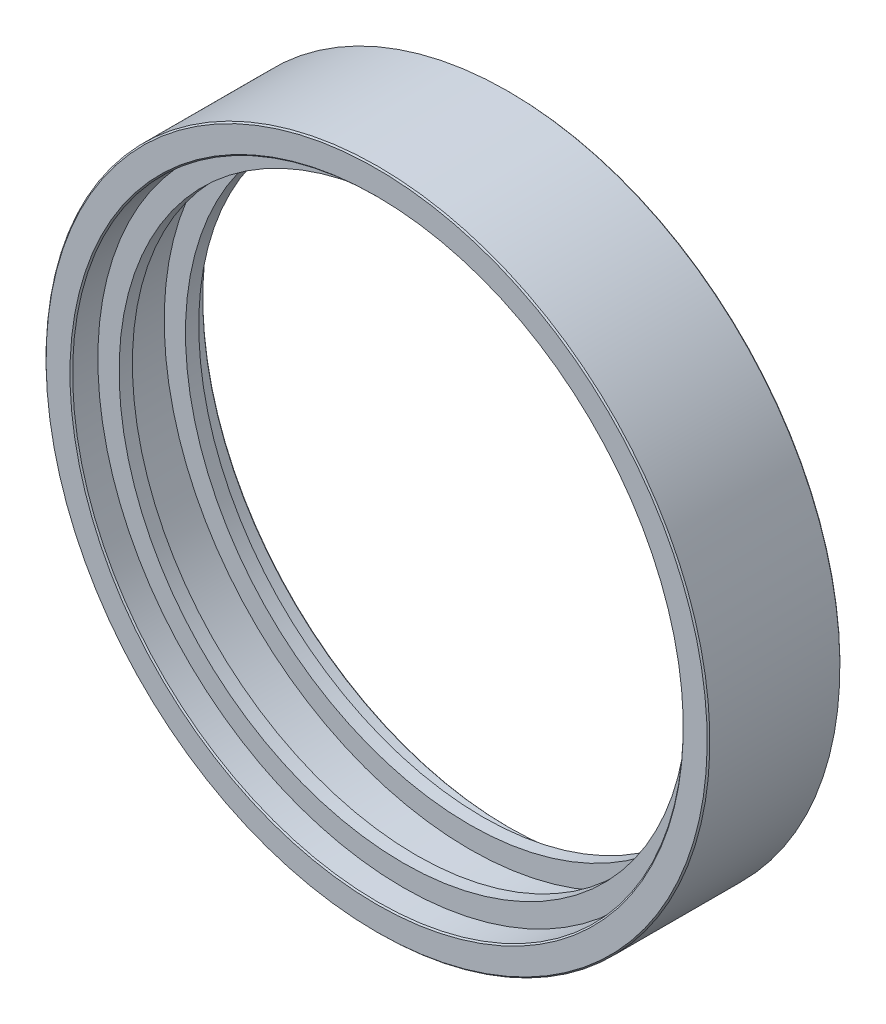
from build123d import *

# Parameters (mm, degrees)
SMUSSO1_SIZE = 0.05


with BuildPart() as part:
    # Schizzo2 → Rivoluzione1 (revolve)
    with BuildSketch(Plane(origin=(0, 0, 0), x_dir=(0, 0, -1), z_dir=(1, 0, 0))):
        Polygon((0.563380282, 12.5), (5.563380282, 12.5), (5.563380282, 11.5), (4.563380282, 11.5), (4.563380282, 10.7), (4.063380282, 10.7), (4.063380282, 11.5), (2.063380282, 11.5), (2.063380282, 10.7), (1.563380282, 10.7), (1.563380282, 11.5), (0.563380282, 11.5), align=None)
    revolve(axis=Axis((0, 0, 0), (0, 0, 1)))

    # Smusso1
    smusso1_edges = [part.edges().sort_by_distance(p)[0] for p in [
        (0, -11.5, -5.563380282),
        (0, -12.5, -5.563380282),
        (0, -12.5, -0.563380282),
        (0, -11.5, -0.563380282),
    ]]
    chamfer(smusso1_edges, length=SMUSSO1_SIZE)


solid = part.part
